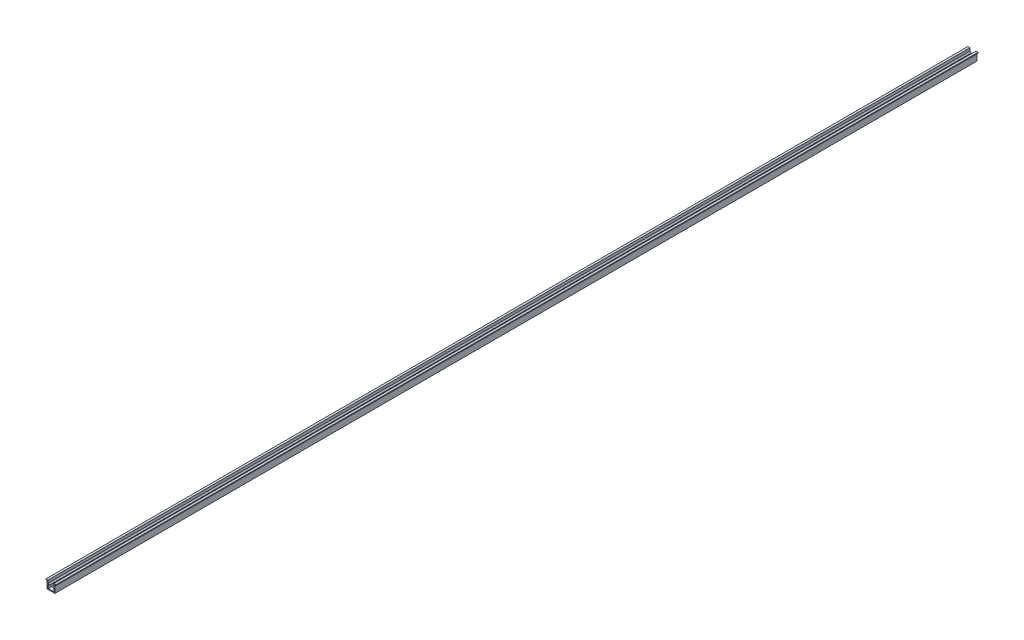
from build123d import *

# Parameters (mm, degrees)
EXTRUDE_1_DEPTH = 1000


with BuildPart() as part:
    # Эскиз1 → Бобышка-Вытянуть1 (new body)
    with BuildSketch(Plane.XY):
        Polygon((4.15, 0), (-4.15, 0), (-4.15, 8), (-5.5, 8), (-5.5, 9), (-3.15, 9), (-3.15, 6), (-1.877207794, 4.727207794), (-2.442893219, 4.161522369), (-3.15, 4.86862915), (-3.15, 1), (3.15, 1), (3.15, 4.86862915), (2.442893219, 4.161522369), (1.877207794, 4.727207794), (3.15, 6), (3.15, 9), (5.5, 9), (5.5, 8), (4.15, 8), align=None)
    extrude(amount=EXTRUDE_1_DEPTH)


solid = part.part
